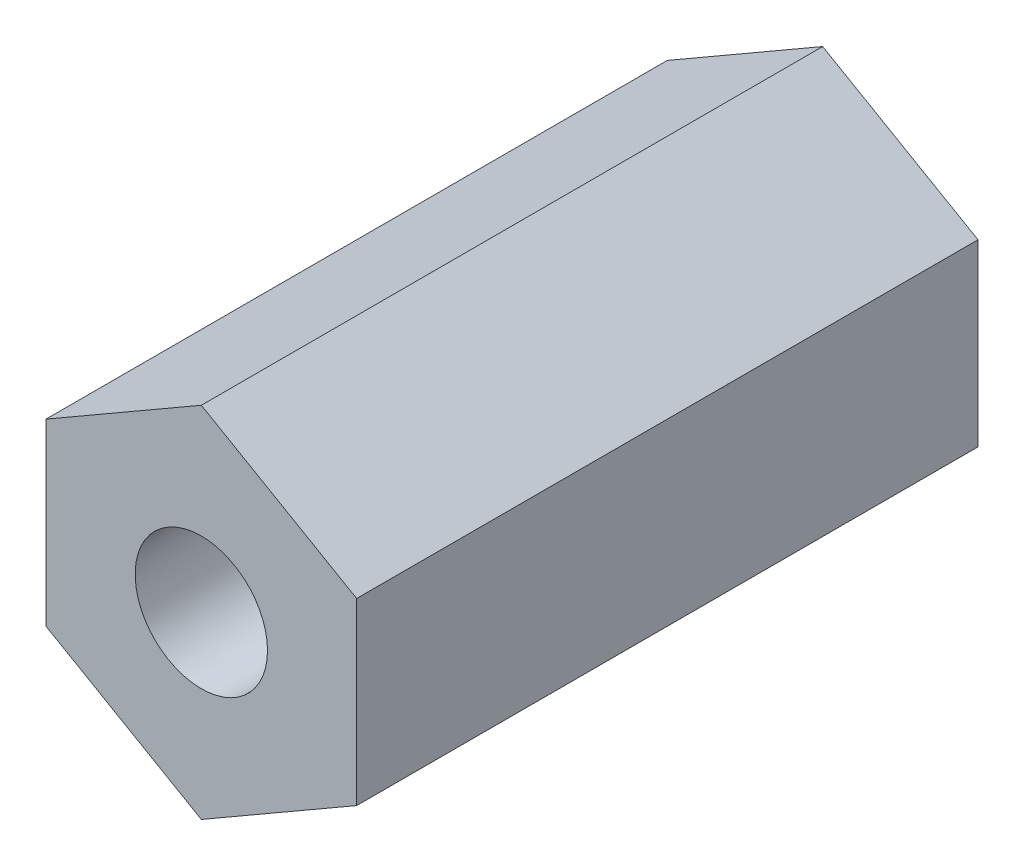
from build123d import *

# Parameters (mm, degrees)
BOSS_EXTRUDE1_DEPTH   = 12.7
F_6_32_TAPPED_HOLE1_D = 2.7051


with BuildPart() as part:
    # Sketch1 → Boss-Extrude1 (new body)
    with BuildSketch(Plane.XY):
        Polygon((0, 3.666174209), (-3.175, 1.833087105), (-3.175, -1.833087105), (0, -3.666174209), (3.175, -1.833087105), (3.175, 1.833087105), align=None)
    extrude(amount=BOSS_EXTRUDE1_DEPTH)

    # #6-32 Tapped Hole1 (through all)
    with Locations(Plane.XY.offset(12.7)):
        with Locations((0, 0)):
            Hole(F_6_32_TAPPED_HOLE1_D / 2)


solid = part.part
